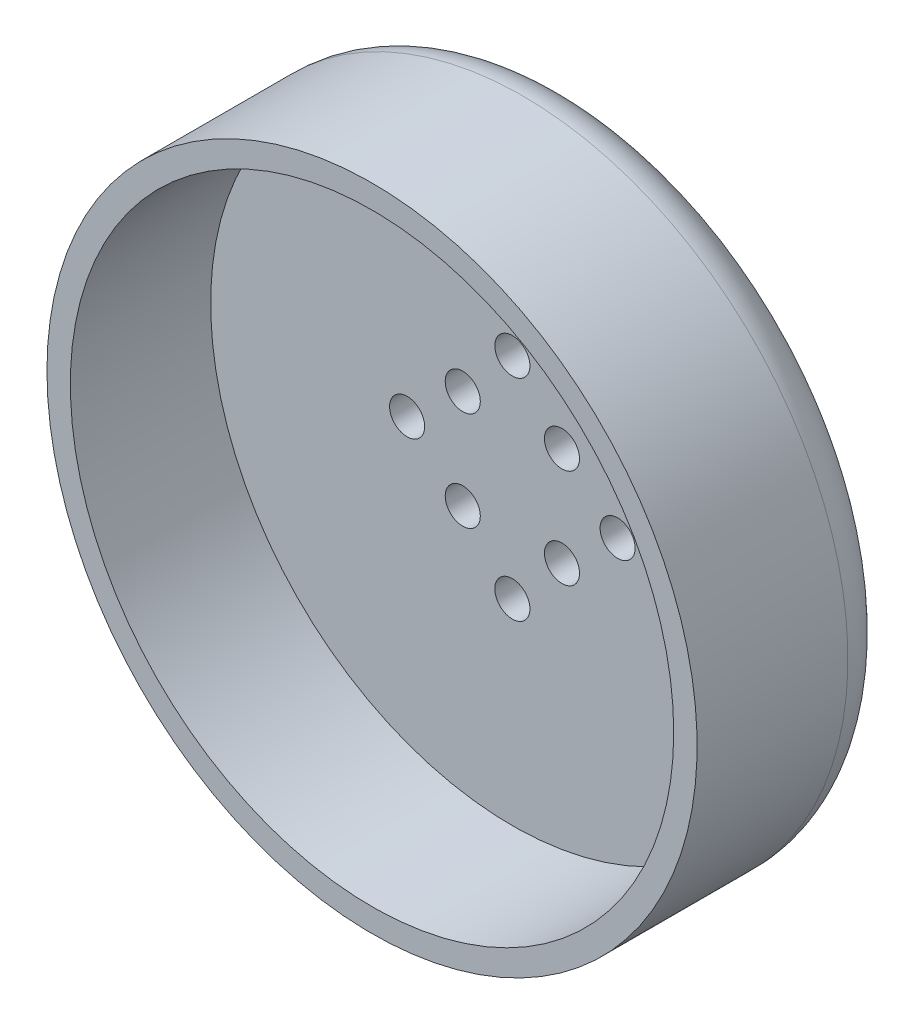
from build123d import *

# Parameters (mm, degrees)
SKETCH3_R          = 1.5
CUT_EXTRUDE1_DEPTH = 19.75
CIRPATTERN1_COUNT  = 4
CHAMFER1_SIZE      = 2.5
CHAMFER1_SIZE2     = 14.178204549
FILLET1_R          = 4
SKETCH4_R          = 25.8
CUT_EXTRUDE2_DEPTH = 12


with BuildPart() as part:
    # Sketch2 → Revolve1 (revolve)
    with BuildSketch(Plane(origin=(0, 0, 0), x_dir=(1, 0, 0), z_dir=(0, 1, 0))):
        Polygon((0, 32), (-2, 32), (-2, 27), (-27.8, 27), (-27.8, 8.25), (0, 8.25), align=None)
    revolve(axis=Axis((0, 0, -88.99), (0, 0, 1)))

    # Sketch3 → Cut-Extrude1 (cut, through all)
    with BuildSketch(Plane(origin=(0, 0, -27), x_dir=(-1, 0, 0), z_dir=(0, 0, -1))):
        with Locations((0, 9)):
            Circle(SKETCH3_R)
        with Locations((4.242640687, 4.242640687)):
            Circle(SKETCH3_R)
    cut_extrude1 = extrude(amount=-CUT_EXTRUDE1_DEPTH, mode=Mode.SUBTRACT)

    # CirPattern1: Cut-Extrude1 ×4 about axis
    cirpattern1_axis = Axis((0, 0, 0), (0, 0, 1))
    for i in range(1, CIRPATTERN1_COUNT):
        add(cut_extrude1.rotate(cirpattern1_axis, i * 360 / CIRPATTERN1_COUNT), mode=Mode.SUBTRACT)

    # Chamfer1
    chamfer1_edges = [part.edges().sort_by_distance(p)[0] for p in [
        (27.8, 0, -27),
    ]]
    chamfer1_side = [part.faces().sort_by_distance(p)[0] for p in [
        (27.8, 0, -17.625),
    ]]
    chamfer(chamfer1_edges, length=CHAMFER1_SIZE, length2=CHAMFER1_SIZE2, reference=chamfer1_side[0])

    # Fillet1
    fillet1_edges = [part.edges().sort_by_distance(p)[0] for p in [
        (27.8, 0, -24.5),
    ]]
    fillet(fillet1_edges, radius=FILLET1_R)

    # Sketch4 → Cut-Extrude2 (cut)
    with BuildSketch(Plane.XY.offset(-8.25)):
        Circle(SKETCH4_R)
    extrude(amount=-CUT_EXTRUDE2_DEPTH, mode=Mode.SUBTRACT)


solid = part.part
